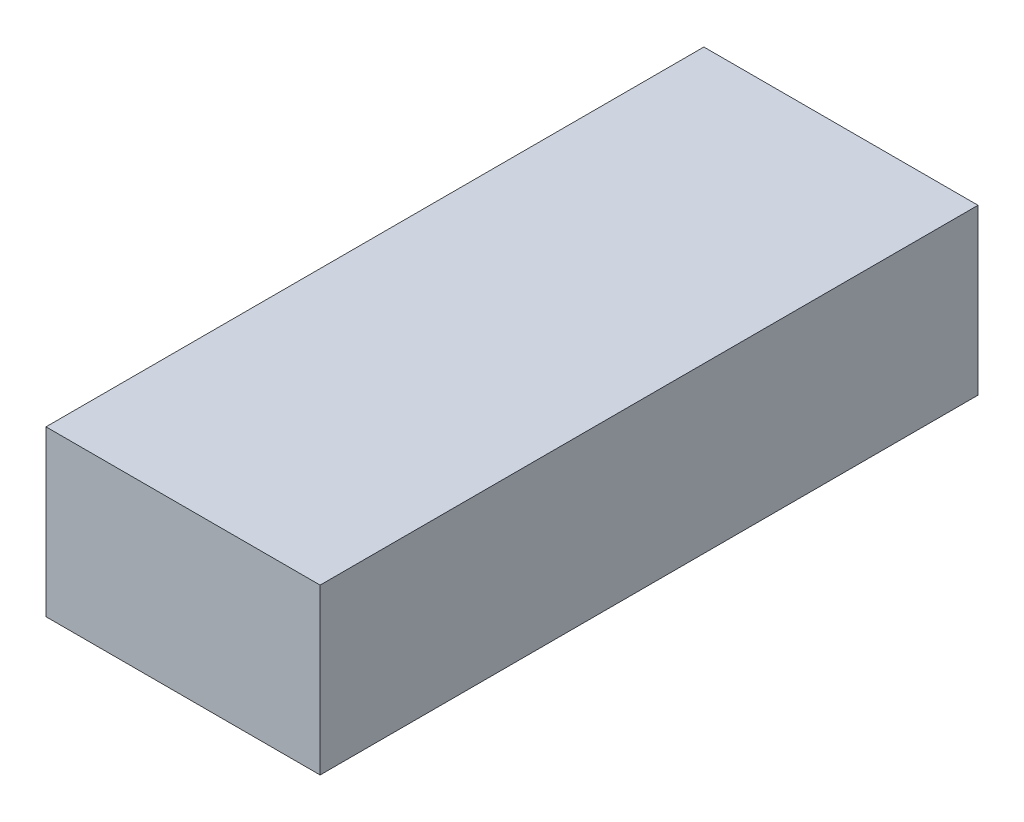
from build123d import *

# Parameters (mm, degrees)
SKETCH1_W           = 5
SKETCH1_H           = 12
BOSS_EXTRUDE1_DEPTH = 3


with BuildPart() as part:
    # Sketch1 → Boss-Extrude1 (new body)
    with BuildSketch(Plane(origin=(0, 0, 0), x_dir=(1, 0, 0), z_dir=(0, 1, 0))):
        Rectangle(SKETCH1_W, SKETCH1_H)
    extrude(amount=BOSS_EXTRUDE1_DEPTH)


solid = part.part
